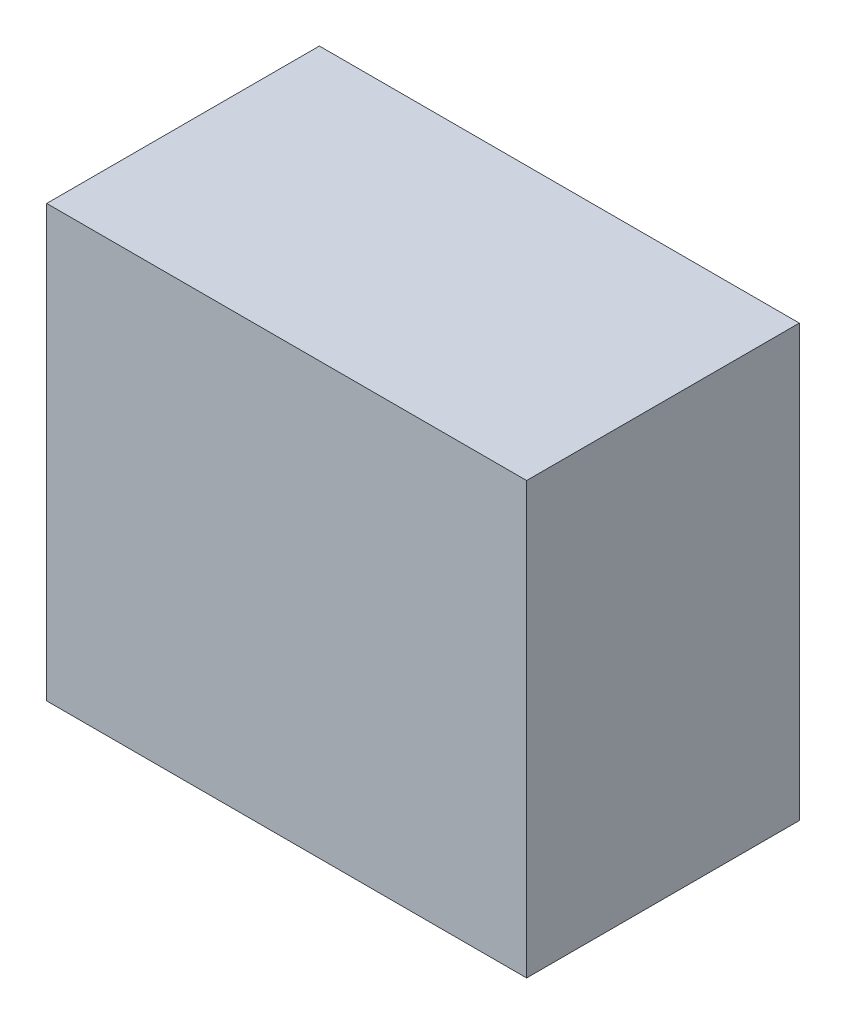
from build123d import *

# Parameters (mm, degrees)
SKETCH1_W      = 22.352
SKETCH1_H      = 20.066
EXTRUDE1_DEPTH = 6.35
SKETCH2_R      = 2.38125
EXTRUDE2_DEPTH = 12.7


with BuildPart() as part:
    # Sketch1 → Extrude1 (new body, symmetric)
    with BuildSketch(Plane.XY):
        Rectangle(SKETCH1_W, SKETCH1_H)
    extrude(amount=EXTRUDE1_DEPTH, both=True)

    # Sketch2 → Extrude2 (cut)
    with BuildSketch(Plane.XZ.offset(10.033)):
        with Locations(Location((0, 0, 0), (0, 0, 270))):  # turned: the seam where the file's is
            Circle(SKETCH2_R)
    extrude(amount=-EXTRUDE2_DEPTH, mode=Mode.SUBTRACT)


solid = part.part
